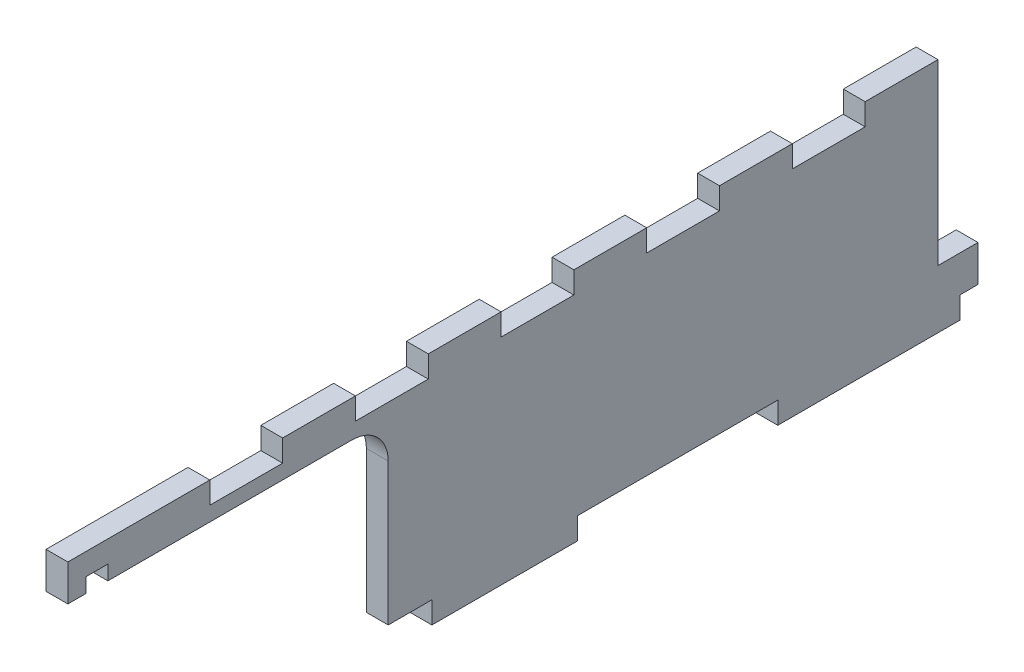
from build123d import *

# Parameters (mm, degrees)
BOSS_EXTRUDE1_DEPTH = 3
CUT_EXTRUDE1_DEPTH  = 6
SKETCH4_W           = 12
SKETCH4_H           = 6
SKETCH4_W_2         = 55
SKETCH4_W_3         = 5
SKETCH4_W_4         = 6
SKETCH4_H_2         = 4
CUT_EXTRUDE2_DEPTH  = 6
CUT_EXTRUDE3_REACH  = 8
SKETCH5_W           = 20
SKETCH5_H           = 6


with BuildPart() as part:
    # Sketch1 → Boss-Extrude1 (new body, symmetric)
    with BuildSketch(Plane(origin=(0, 0, 0), x_dir=(0, 0, -1), z_dir=(1, 0, 0))):
        Polygon((0, 0), (250, 0), (250, 65), (60, 65), (0, 65), align=None)
    extrude(amount=BOSS_EXTRUDE1_DEPTH, both=True)

    # Sketch3 → Cut-Extrude1 (cut)
    with BuildSketch(Plane(origin=(3, 0, 0), x_dir=(0, 0, -1), z_dir=(1, 0, 0))):
        with BuildLine():
            Line((0, 0), (88, 0))
            Line((88, 0), (88, 45))
            ThreePointArc((88, 45), (85.071067812, 52.071067812), (78, 55))
            Line((78, 55), (0, 55))
            Line((0, 55), (0, 0))
        make_face()
    extrude(amount=-CUT_EXTRUDE1_DEPTH, mode=Mode.SUBTRACT)

    # Sketch4 → Cut-Extrude2 (cut)
    with BuildSketch(Plane(origin=(3, 0, 0), x_dir=(0, 0, -1), z_dir=(1, 0, 0))):
        with Locations((94, 3)):
            Rectangle(SKETCH4_W, SKETCH4_H)
        with Locations((167.5, 3)):
            Rectangle(SKETCH4_W_2, SKETCH4_H)
        with Locations((247.5, 3)):
            Rectangle(SKETCH4_W_3, SKETCH4_H)
        Polygon((245, 16), (250, 16), (250, 65), (239, 65), (239, 16), align=None)
        with Locations((8, 57)):
            Rectangle(SKETCH4_W_4, SKETCH4_H_2)
    extrude(amount=-CUT_EXTRUDE2_DEPTH, mode=Mode.SUBTRACT)

    # Sketch5 → Cut-Extrude3 (cut, up to next)
    with BuildSketch(Plane(origin=(3, 0, 0), x_dir=(0, 0, -1), z_dir=(1, 0, 0)), mode=Mode.PRIVATE) as cut_extrude3_sk1:
        with Locations((169, 62)):
            Rectangle(SKETCH5_W, SKETCH5_H)
    cut_extrude3_tool1 = extrude(cut_extrude3_sk1.sketch, amount=-CUT_EXTRUDE3_REACH, mode=Mode.PRIVATE) & part.part
    add(cut_extrude3_tool1.solids().sort_by_distance((3, 62, -169))[0], mode=Mode.SUBTRACT)
    # Sketch5 → Cut-Extrude3 (cut, up to next)
    with BuildSketch(Plane(origin=(3, 0, 0), x_dir=(0, 0, -1), z_dir=(1, 0, 0)), mode=Mode.PRIVATE) as cut_extrude3_sk2:
        with Locations((209, 62)):
            Rectangle(SKETCH5_W, SKETCH5_H)
    cut_extrude3_tool2 = extrude(cut_extrude3_sk2.sketch, amount=-CUT_EXTRUDE3_REACH, mode=Mode.PRIVATE) & part.part
    add(cut_extrude3_tool2.solids().sort_by_distance((3, 62, -209))[0], mode=Mode.SUBTRACT)
    # Sketch5 → Cut-Extrude3 (cut, up to next)
    with BuildSketch(Plane(origin=(3, 0, 0), x_dir=(0, 0, -1), z_dir=(1, 0, 0)), mode=Mode.PRIVATE) as cut_extrude3_sk3:
        with Locations((129, 62)):
            Rectangle(SKETCH5_W, SKETCH5_H)
    cut_extrude3_tool3 = extrude(cut_extrude3_sk3.sketch, amount=-CUT_EXTRUDE3_REACH, mode=Mode.PRIVATE) & part.part
    add(cut_extrude3_tool3.solids().sort_by_distance((3, 62, -129))[0], mode=Mode.SUBTRACT)
    # Sketch5 → Cut-Extrude3 (cut, up to next)
    with BuildSketch(Plane(origin=(3, 0, 0), x_dir=(0, 0, -1), z_dir=(1, 0, 0)), mode=Mode.PRIVATE) as cut_extrude3_sk4:
        with Locations((89, 62)):
            Rectangle(SKETCH5_W, SKETCH5_H)
    cut_extrude3_tool4 = extrude(cut_extrude3_sk4.sketch, amount=-CUT_EXTRUDE3_REACH, mode=Mode.PRIVATE) & part.part
    add(cut_extrude3_tool4.solids().sort_by_distance((3, 62, -89))[0], mode=Mode.SUBTRACT)
    # Sketch5 → Cut-Extrude3 (cut, up to next)
    with BuildSketch(Plane(origin=(3, 0, 0), x_dir=(0, 0, -1), z_dir=(1, 0, 0)), mode=Mode.PRIVATE) as cut_extrude3_sk5:
        with Locations((49, 62)):
            Rectangle(SKETCH5_W, SKETCH5_H)
    cut_extrude3_tool5 = extrude(cut_extrude3_sk5.sketch, amount=-CUT_EXTRUDE3_REACH, mode=Mode.PRIVATE) & part.part
    add(cut_extrude3_tool5.solids().sort_by_distance((3, 62, -49))[0], mode=Mode.SUBTRACT)


solid = part.part
